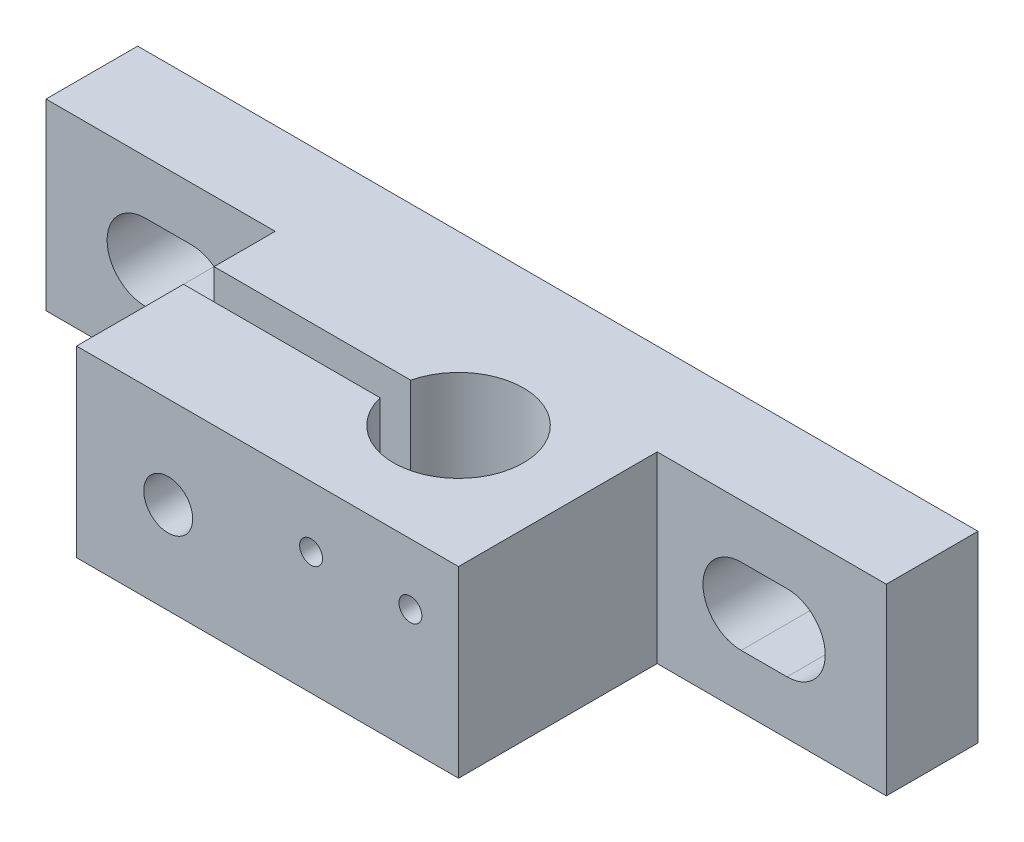
from build123d import *

# Parameters (mm, degrees)
SKETCH2_W           = 55
SKETCH2_H           = 12
BOSS_EXTRUDE1_DEPTH = 6
SKETCH3_W           = 25
SKETCH3_H           = 12
BOSS_EXTRUDE2_DEPTH = 13
SKETCH4_R           = 4.25
CUT_EXTRUDE2_DEPTH  = 30
SKETCH5_W           = 20.513890507
SKETCH5_H           = 7
CUT_EXTRUDE3_DEPTH  = 5
SKETCH6_R           = 1.6
CUT_EXTRUDE4_DEPTH  = 11
CUT_EXTRUDE5_DEPTH  = 3
SKETCH8_R           = 0.75
CUT_EXTRUDE6_DEPTH  = 3


with BuildPart() as part:
    # Sketch2 → Boss-Extrude1 (new body)
    with BuildSketch(Plane.XY):
        with Locations((27.5, 6)):
            Rectangle(SKETCH2_W, SKETCH2_H)
        with BuildLine():
            Line((6.5, 8.5), (9.5, 8.5))
            ThreePointArc((9.5, 8.5), (12, 6), (9.5, 3.5))
            Line((9.5, 3.5), (6.5, 3.5))
            ThreePointArc((6.5, 3.5), (4, 6), (6.5, 8.5))
        make_face(mode=Mode.SUBTRACT)
        with BuildLine():
            Line((48.5, 8.5), (45.5, 8.5))
            ThreePointArc((45.5, 8.5), (43, 6), (45.5, 3.5))
            Line((45.5, 3.5), (48.5, 3.5))
            ThreePointArc((48.5, 3.5), (51, 6), (48.5, 8.5))
        make_face(mode=Mode.SUBTRACT)
    extrude(amount=BOSS_EXTRUDE1_DEPTH)

    # Sketch3 → Boss-Extrude2 (add)
    with BuildSketch(Plane.XY.offset(6)):
        with Locations((27.5, 6)):
            Rectangle(SKETCH3_W, SKETCH3_H)
    extrude(amount=BOSS_EXTRUDE2_DEPTH)

    # Sketch4 → Cut-Extrude2 (cut)
    with BuildSketch(Plane.XZ):
        with BuildLine():
            ThreePointArc((27.86932209, 10), (27.75, 11), (27.86932209, 12))
            Line((27.86932209, 12), (15, 12))
            Line((15, 12), (15, 10))
            Line((15, 10), (27.86932209, 10))
        make_face()
        with Locations((32, 11)):
            Circle(SKETCH4_R)
    extrude(amount=-CUT_EXTRUDE2_DEPTH, mode=Mode.SUBTRACT)

    # Sketch5 → Cut-Extrude3 (cut)
    with BuildSketch(Plane(origin=(0, 0, 0), x_dir=(-1, 0, 0), z_dir=(0, 0, -1))):
        with Locations((-27.415473723, 6)):
            Rectangle(SKETCH5_W, SKETCH5_H)
    extrude(amount=-CUT_EXTRUDE3_DEPTH, mode=Mode.SUBTRACT)

    # Sketch6 → Cut-Extrude4 (cut)
    with BuildSketch(Plane.XY.offset(19)):
        with Locations((21, 6)):
            Circle(SKETCH6_R)
    extrude(amount=-CUT_EXTRUDE4_DEPTH, mode=Mode.SUBTRACT)

    # Sketch7 → Cut-Extrude5 (cut)
    with BuildSketch(Plane(origin=(0, 0, 5), x_dir=(-1, 0, 0), z_dir=(0, 0, -1))):
        Polygon((-17.535898385, 6), (-19.267949192, 9), (-22.732050808, 9), (-24.464101615, 6), (-22.732050808, 3), (-19.267949192, 3), align=None)
    extrude(amount=-CUT_EXTRUDE5_DEPTH, mode=Mode.SUBTRACT)

    # Sketch8 → Cut-Extrude6 (cut)
    with BuildSketch(Plane.XY.offset(19)):
        with Locations((36.85, 8)):
            Circle(SKETCH8_R)
        with Locations((30.35, 8)):
            Circle(SKETCH8_R)
    extrude(amount=-CUT_EXTRUDE6_DEPTH, mode=Mode.SUBTRACT)


solid = part.part
